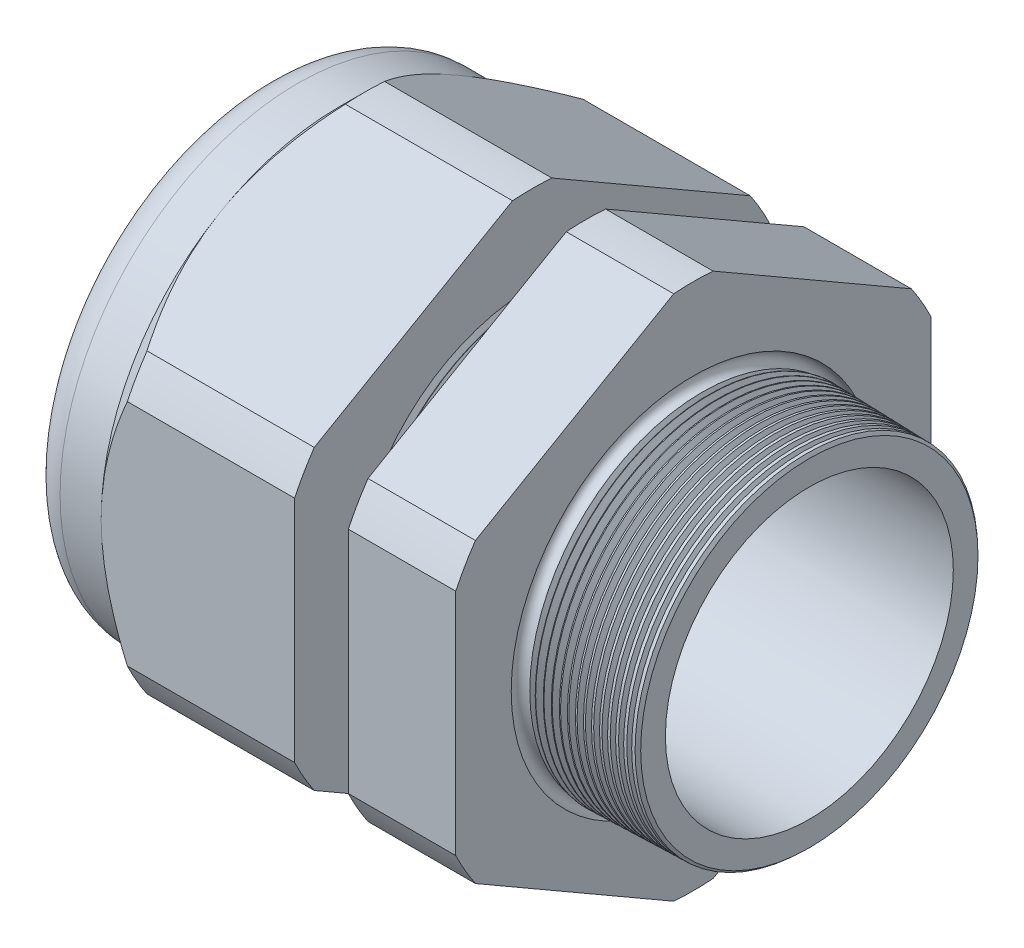
from build123d import *

# Parameters (mm, degrees)
SKETCH12_OUTSIDE_W = 140.582
SKETCH12_OUTSIDE_H = 140.582
CUT_EXTRUDE2_DEPTH = 53.5600168
FILLET4_R          = 3.81
SKETCH19_OUTSIDE_W = 83.088
SKETCH19_OUTSIDE_H = 88.928
SKETCH19_OUTSIDE_R = 26.543
CUT_EXTRUDE3_DEPTH = 3.99796
CUT_EXTRUDE3_DRAFT = -45
CHAMFER1_SIZE      = 0.260919487
CHAMFER1_SIZE2     = 0.254
SKETCH21_R         = 16.002
PLUG_DEPTH         = 12.7
SKETCH22_R         = 15.748
CUT_EXTRUDE4_DEPTH = 0.508
SKETCH27_R         = 3.937
PLUGHOLES_DEPTH    = 61.452
CIRPATTERN1_COUNT  = 6
LPATTERN1_COUNT    = 8
LPATTERN1_PITCH    = 0.762
LPATTERN2_COUNT    = 15
LPATTERN2_PITCH    = 0.889
SKETCH32_R         = 0.889


with BuildPart() as part:
    # Sketch10 → Revolve2 (revolve)
    with BuildSketch(Plane.XY, mode=Mode.PRIVATE) as revolve2_sk:
        Polygon((-55.88, 16.002), (-25.87759112, 16.002), (5.08, 16.080346947), (5.08, 19.128346947), (-7.874, 19.467559375), (-7.874, 53.086), (-19.873976, 53.086), (-19.873976, 19.781789805), (-25.87759112, 19.939), (-25.87759112, 53.086), (-47.4800168, 53.086), (-47.4800168, 26.543), (-55.88, 26.543), align=None)
    revolve(revolve2_sk.sketch.rotate(Axis((0, 0, 0), (-1, 0, 0)), 90), axis=Axis((0, 0, 0), (-1, 0, 0)))  # turned: the seam where the file's is

    # Sketch12 outside → Cut-Extrude2 (cut, through all)
    with BuildSketch(Plane.ZY.offset(47.4800168)):
        Rectangle(SKETCH12_OUTSIDE_W, SKETCH12_OUTSIDE_H)
        with BuildLine():
            Line((-2.19715092, 29.380690715), (-24.34584908, 16.59313387))
            ThreePointArc((-24.34584908, 16.59313387), (-25.515472645, 14.731365), (-26.543, 12.787556845))
            Line((-26.543, 12.787556845), (-26.543, -12.787556845))
            ThreePointArc((-26.543, -12.787556845), (-25.515472645, -14.731365), (-24.34584908, -16.59313387))
            Line((-24.34584908, -16.59313387), (-2.19715092, -29.380690715))
            ThreePointArc((-2.19715092, -29.380690715), (0, -29.46273), (2.19715092, -29.380690715))
            Line((2.19715092, -29.380690715), (24.34584908, -16.59313387))
            ThreePointArc((24.34584908, -16.59313387), (25.515472645, -14.731365), (26.543, -12.787556845))
            Line((26.543, -12.787556845), (26.543, 12.787556845))
            ThreePointArc((26.543, 12.787556845), (25.515472645, 14.731365), (24.34584908, 16.59313387))
            Line((24.34584908, 16.59313387), (2.19715092, 29.380690715))
            ThreePointArc((2.19715092, 29.380690715), (0, 29.46273), (-2.19715092, 29.380690715))
        make_face(mode=Mode.SUBTRACT)
    extrude(amount=-CUT_EXTRUDE2_DEPTH, mode=Mode.SUBTRACT)

    # Fillet4
    fillet4_edges = [part.edges().sort_by_distance(p)[0] for p in [
        (-55.88, 0, 26.543),
    ]]
    fillet(fillet4_edges, radius=FILLET4_R)


with BuildPart() as cut_extrude3_tool:
    # Sketch19 outside → Cut-Extrude3 (with draft: the straight prism first)
    with BuildSketch(Plane.ZY.offset(47.4800168)):
        Rectangle(SKETCH19_OUTSIDE_W, SKETCH19_OUTSIDE_H)
        Circle(SKETCH19_OUTSIDE_R, mode=Mode.SUBTRACT)
    extrude(amount=-CUT_EXTRUDE3_DEPTH)
    # Cut-Extrude3: the draft: its side faces are tilted about the plane it starts from
    cut_extrude3_sides = [cut_extrude3_tool.faces().sort_by_distance(p)[0] for p in [
        (-45.4810368, -44.464, 0),
        (-45.4810368, 0, 41.544),
        (-45.4810368, 44.464, 0),
        (-45.4810368, 0, -41.544),
        (-45.4810368, 0, -26.543),
    ]]
    draft(cut_extrude3_sides, Plane.ZY.offset(47.4800168), CUT_EXTRUDE3_DRAFT)


with BuildPart() as part_1:
    add(part.part)

    # Cut-Extrude3: cut by cut_extrude3_tool
    add(cut_extrude3_tool.part, mode=Mode.SUBTRACT)

    # Chamfer1
    chamfer1_edges = [part_1.edges().sort_by_distance(p)[0] for p in [
        (5.08, 0, 19.128346947),
    ]]
    chamfer1_side = [part_1.faces().sort_by_distance(p)[0] for p in [
        (5.08, 0, 16.621378301),
    ]]
    chamfer(chamfer1_edges, length=CHAMFER1_SIZE, length2=CHAMFER1_SIZE2, reference=chamfer1_side[0])

    # Sketch29 → Cut-Revolve1 (revolve, cut)
    with BuildSketch(Plane.XY, mode=Mode.PRIVATE) as cut_revolve1_sk:
        Polygon((-25.87759112, 19.939), (-25.144607539, 19.919806149), (-25.527721692, 19.294620673), align=None)
    cut_revolve1 = revolve(cut_revolve1_sk.sketch.rotate(Axis((0, 0, 0), (-1, 0, 0)), 90), axis=Axis((0, 0, 0), (-1, 0, 0)), mode=Mode.SUBTRACT)  # turned: the seam where the file's is

    # LPattern1: Cut-Revolve1 ×8
    with Locations(*[(i * LPATTERN1_PITCH, 0, 0) for i in range(1, LPATTERN1_COUNT)]):
        add(cut_revolve1, mode=Mode.SUBTRACT)

    # Sketch30 → Cut-Revolve2 (revolve, cut)
    with BuildSketch(Plane.XY, mode=Mode.PRIVATE) as cut_revolve2_sk:
        Polygon((-7.874, 19.467559375), (-6.994419703, 19.444526754), (-7.454156686, 18.694304183), align=None)
    cut_revolve2 = revolve(cut_revolve2_sk.sketch.rotate(Axis((0, 0, 0), (-1, 0, 0)), 270), axis=Axis((0, 0, 0), (-1, 0, 0)), mode=Mode.SUBTRACT)  # turned: the seam where the file's is

    # LPattern2: Cut-Revolve2 ×15
    with Locations(*[(i * LPATTERN2_PITCH, 0, 0) for i in range(1, LPATTERN2_COUNT)]):
        add(cut_revolve2, mode=Mode.SUBTRACT)

    # Sketch32 → Cut-Revolve3 (revolve, cut)
    with BuildSketch(Plane.XY, mode=Mode.PRIVATE) as cut_revolve3_sk:
        with Locations((-7.747, 19.467559375)):
            Circle(SKETCH32_R)
    revolve(cut_revolve3_sk.sketch.rotate(Axis((0, 0, 0), (-1, 0, 0)), 270), axis=Axis((0, 0, 0), (-1, 0, 0)), mode=Mode.SUBTRACT)  # turned: the seam where the file's is


with BuildPart() as body_2:
    # Sketch21 → plug (new body)
    with BuildSketch(Plane.ZY.offset(55.88)):
        Circle(SKETCH21_R)
    extrude(amount=-PLUG_DEPTH)

    # Sketch22 → Cut-Extrude4 (cut)
    with BuildSketch(Plane.ZY.offset(55.88)):
        Circle(SKETCH22_R)
    extrude(amount=-CUT_EXTRUDE4_DEPTH, mode=Mode.SUBTRACT)

    # Sketch27 → plugholes (cut, through all)
    with BuildSketch(Plane.ZY.offset(55.372)):
        with Locations((-11.795252, 0)):
            Circle(SKETCH27_R)
    plugholes = extrude(amount=-PLUGHOLES_DEPTH, mode=Mode.SUBTRACT)

    # CirPattern1: plugholes ×6 about axis
    cirpattern1_axis = Axis((0, 0, 0), (1, 0, 0))
    for i in range(1, CIRPATTERN1_COUNT):
        add(plugholes.rotate(cirpattern1_axis, i * 360 / CIRPATTERN1_COUNT), mode=Mode.SUBTRACT)


solid = Compound([part_1.part, body_2.part])
